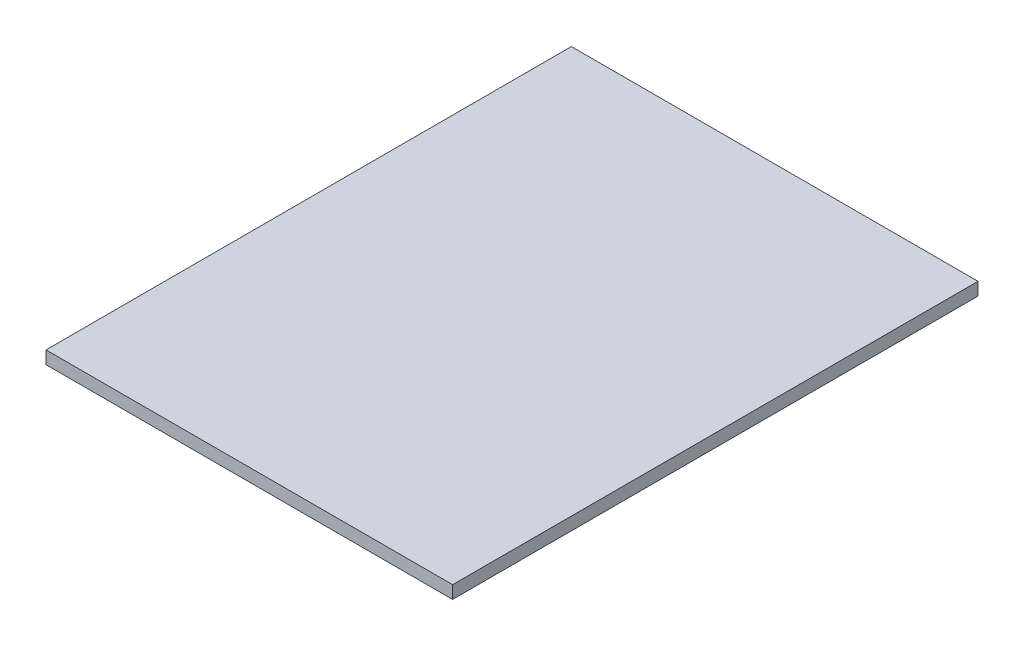
from build123d import *

# Parameters (mm, degrees)
SKETCH1_W           = 12.7
SKETCH1_H           = 16.41
BOSS_EXTRUDE1_DEPTH = 0.4


with BuildPart() as part:
    # Sketch1 → Boss-Extrude1 (new body)
    with BuildSketch(Plane(origin=(0, 0, 0), x_dir=(1, 0, 0), z_dir=(0, 1, 0))):
        Rectangle(SKETCH1_W, SKETCH1_H)
    extrude(amount=BOSS_EXTRUDE1_DEPTH)


solid = part.part
